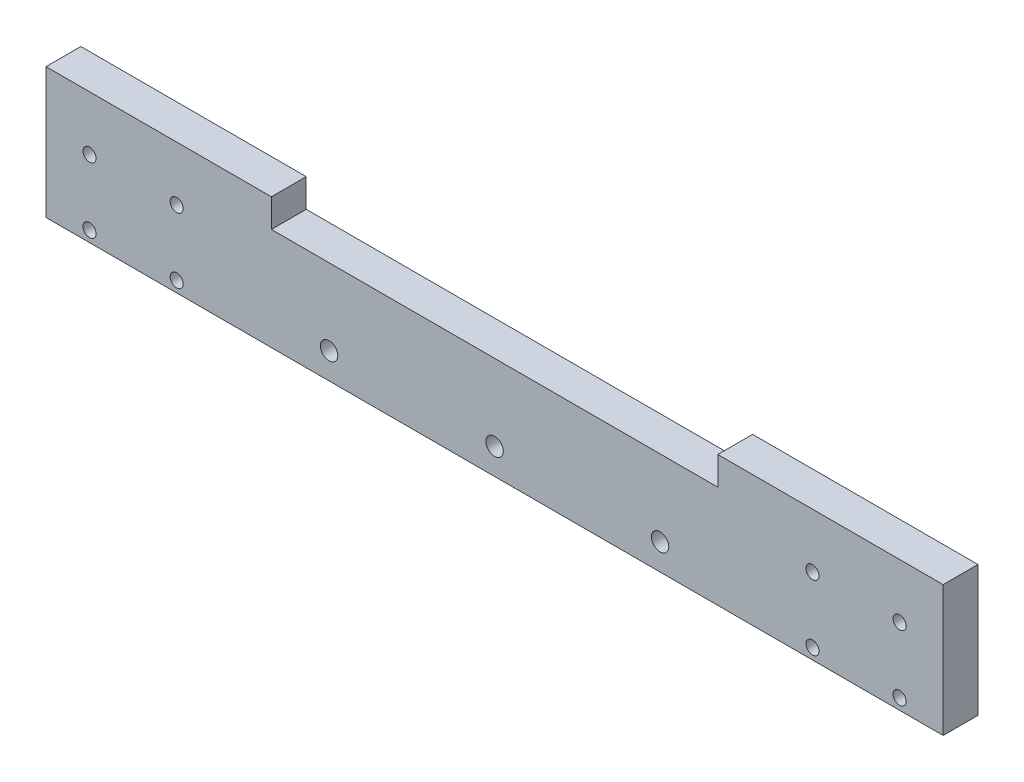
from build123d import *

# Parameters (mm, degrees)
BOSS_EXTRU_1_DEPTH      = 8
ESQUISSE2_R             = 2
ENL_V_MAT_EXTRU_1_DEPTH = 9
ESQUISSE3_R             = 1.5
ENL_V_MAT_EXTRU_2_DEPTH = 5


with BuildPart() as part:
    # Esquisse1 → Boss.-Extru.1 (new body)
    with BuildSketch(Plane.XY):
        Polygon((0, 30), (0, 0), (206, 0), (206, 30), (154.25, 30), (154.25, 23.5), (51.75, 23.5), (51.75, 30), align=None)
    extrude(amount=BOSS_EXTRU_1_DEPTH)

    # Esquisse2 → Enlèv. mat.-Extru.1 (cut, through all)
    with BuildSketch(Plane.XY.offset(8)):
        with Locations((103, 6)):
            Circle(ESQUISSE2_R)
        with Locations((141, 6)):
            Circle(ESQUISSE2_R)
        with Locations((65, 6)):
            Circle(ESQUISSE2_R)
    extrude(amount=-ENL_V_MAT_EXTRU_1_DEPTH, mode=Mode.SUBTRACT)

    # Esquisse3 → Enlèv. mat.-Extru.2 (cut)
    with BuildSketch(Plane.XY.offset(8)):
        with Locations((176, 17.5)):
            Circle(ESQUISSE3_R)
        with Locations((196, 17.5)):
            Circle(ESQUISSE3_R)
        with Locations((196, 2.5)):
            Circle(ESQUISSE3_R)
        with Locations((176, 2.5)):
            Circle(ESQUISSE3_R)
    enl_v_mat_extru_2 = extrude(amount=-ENL_V_MAT_EXTRU_2_DEPTH, mode=Mode.SUBTRACT)

    # Symétrie1: Enlèv. mat.-Extru.2 across plane
    add(enl_v_mat_extru_2.mirror(Plane(origin=(103, 0, 0), x_dir=(0, 0, 1), z_dir=(1, 0, 0))), mode=Mode.SUBTRACT)


solid = part.part
